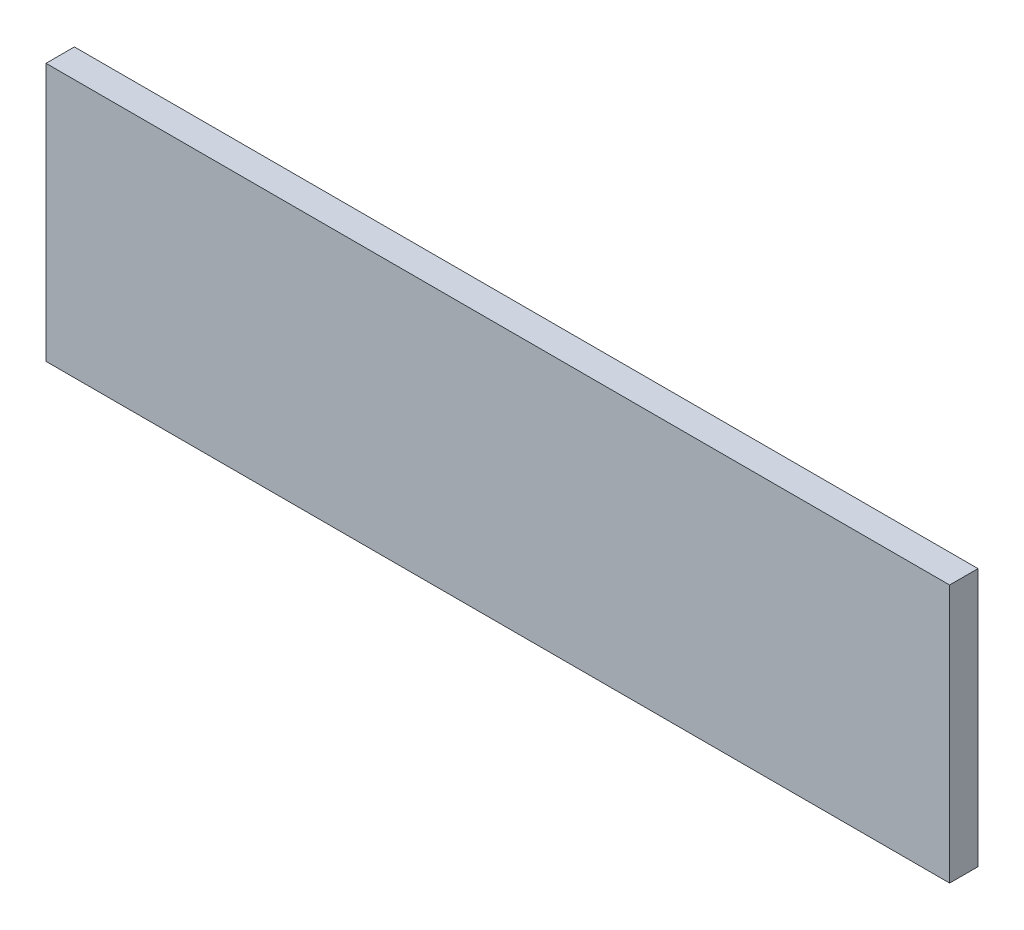
from build123d import *

# Parameters (mm, degrees)
SKETCH2_W           = 350
SKETCH2_H           = 100
BOSS_EXTRUDE1_DEPTH = 11


with BuildPart() as part:
    # Sketch2 → Boss-Extrude1 (new body)
    with BuildSketch(Plane.XY):
        with Locations((40.6, 9.266666667)):
            Rectangle(SKETCH2_W, SKETCH2_H)
    extrude(amount=BOSS_EXTRUDE1_DEPTH)


solid = part.part
